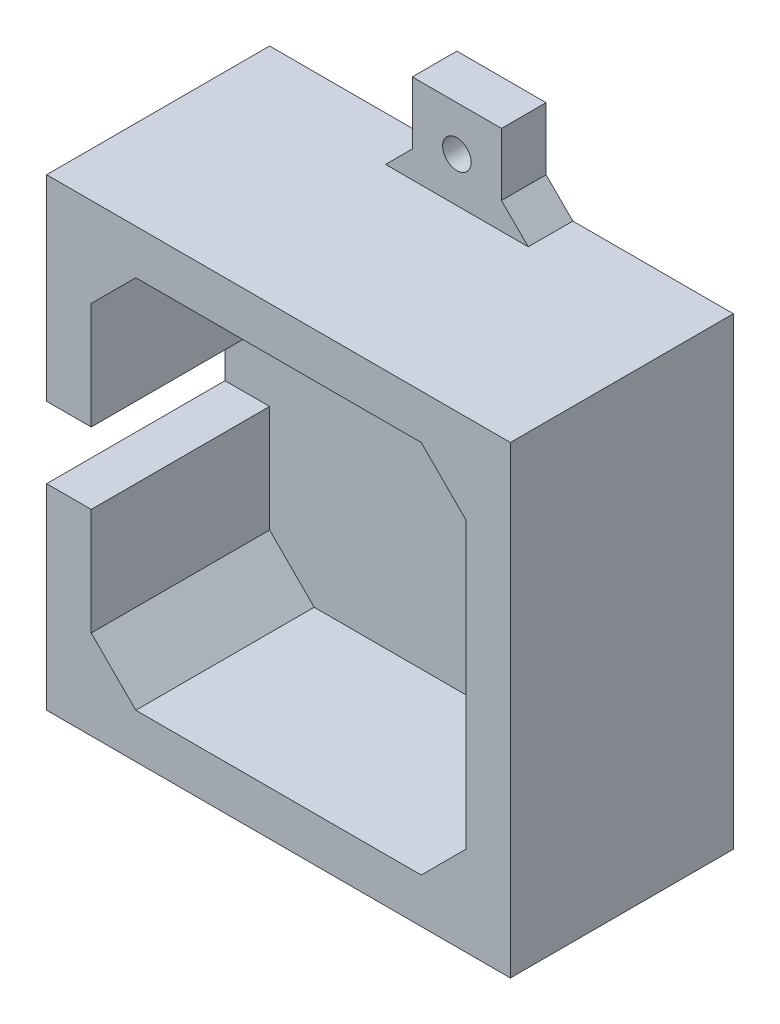
from build123d import *

# Parameters (mm, degrees)
IZIM1_W                     = 52
IZIM1_H                     = 52
Y_KSEKLIK_EKSTR_ZYON4_DEPTH = 20
IZIM3_W                     = 5
IZIM3_H                     = 52
Y_KSEKLIK_EKSTR_ZYON5_DEPTH = 52
KES_EKSTR_ZYON2_DEPTH       = 33
IZIM6_R                     = 1.6
IZIM6_W                     = 10
IZIM6_H                     = 10
Y_KSEKLIK_EKSTR_ZYON6_DEPTH = 5
PAH3_SIZE                   = 3
IZIM7_W                     = 15.209944983
IZIM7_H                     = 8
KES_EKSTR_ZYON3_DEPTH       = 16


with BuildPart() as part:
    # Çizim1 → Yükseklik-Ekstrüzyon4 (new body)
    with BuildSketch(Plane.XY):
        with Locations((21, 22.170509087)):
            Rectangle(IZIM1_W, IZIM1_H)
        Polygon((5, 1.170509087), (37, 1.170509087), (42, 6.170509087), (42, 38.170509087), (37, 43.170509087), (5, 43.170509087), (0, 38.170509087), (0, 6.170509087), align=None, mode=Mode.SUBTRACT)
    extrude(amount=Y_KSEKLIK_EKSTR_ZYON4_DEPTH)

    # Çizim3 → Yükseklik-Ekstrüzyon5 (add)
    with BuildSketch(Plane(origin=(47, 0, 0), x_dir=(0, 0, -1), z_dir=(1, 0, 0))):
        with Locations((2.5, 22.170509087)):
            Rectangle(IZIM3_W, IZIM3_H)
    extrude(amount=-Y_KSEKLIK_EKSTR_ZYON5_DEPTH)

    # Çizim5 → Kes-Ekstrüzyon2 (cut)
    with BuildSketch(Plane.ZY.offset(5)):
        Polygon((0, 18.170509087), (0, 22.170509087), (0, 26.170509087), (8, 26.170509087), (8, 18.170509087), align=None)
    extrude(amount=-KES_EKSTR_ZYON2_DEPTH, mode=Mode.SUBTRACT)

    # Çizim6 → Yükseklik-Ekstrüzyon6 (add)
    with BuildSketch(Plane(origin=(0, 0, -5), x_dir=(-1, 0, 0), z_dir=(0, 0, -1))):
        Polygon((-26, 58.170509087), (-21, 58.170509087), (-16, 58.170509087), (-16, 48.170509087), (-26, 48.170509087), align=None)
        with Locations((-21, 53.170509087)):
            Circle(IZIM6_R, mode=Mode.SUBTRACT)
        with Locations((-21, -8.829490913)):
            Rectangle(IZIM6_W, IZIM6_H)
        with Locations((-21, -8.829490913)):
            Circle(IZIM6_R, mode=Mode.SUBTRACT)
    extrude(amount=-Y_KSEKLIK_EKSTR_ZYON6_DEPTH)

    # Pah3
    pah3_edges = [part.edges().sort_by_distance(p)[0] for p in [
        (26, -3.829490913, -2.5),
        (16, -3.829490913, -2.5),
        (16, 48.170509087, -2.5),
        (26, 48.170509087, -2.5),
    ]]
    chamfer(pah3_edges, length=PAH3_SIZE)

    # Çizim7 → Kes-Ekstrüzyon3 (cut)
    with BuildSketch(Plane.ZY.offset(5)):
        with Locations((15.604972491, 22.170509087)):
            Rectangle(IZIM7_W, IZIM7_H)
    extrude(amount=-KES_EKSTR_ZYON3_DEPTH, mode=Mode.SUBTRACT)


solid = part.part
